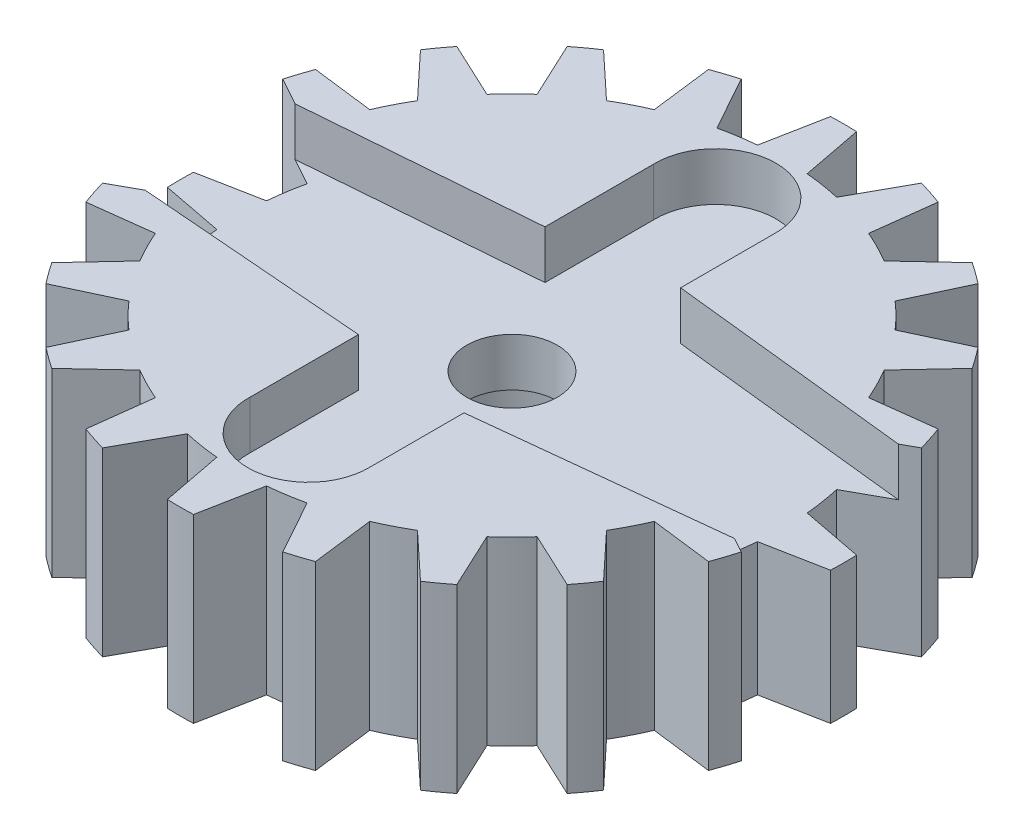
from build123d import *

# Parameters (mm, degrees)
SKETCH1_R           = 11
SKETCH1_R_2         = 1.5
BOSS_EXTRUDE1_DEPTH = 6
CUT_EXTRUDE1_DEPTH  = 6
CIRPATTERN1_COUNT   = 20
SKETCH3_R           = 1.25
CUT_EXTRUDE2_DEPTH  = 1.6
SKETCH4_R           = 2.6
CUT_EXTRUDE3_DEPTH  = 2.8


with BuildPart() as part:
    # Sketch1 → Boss-Extrude1 (new body)
    with BuildSketch(Plane(origin=(0, 0, 0), x_dir=(1, 0, 0), z_dir=(0, 1, 0))):
        Circle(SKETCH1_R)
        Circle(SKETCH1_R_2, mode=Mode.SUBTRACT)
    extrude(amount=BOSS_EXTRUDE1_DEPTH)

    # Sketch2 → Cut-Extrude1 (cut)
    with BuildSketch(Plane(origin=(0, 6, 0), x_dir=(1, 0, 0), z_dir=(0, 1, 0))):
        with BuildLine():
            Line((-0.823514568, 8.962244348), (-0.431857973, 10.991519399))
            ThreePointArc((-0.431857973, 10.991519399), (0, 11), (0.431857973, 10.991519399))
            Line((0.431857973, 10.991519399), (0.823514568, 8.962244348))
            ThreePointArc((0.823514568, 8.962244348), (1.116310063, 8.930501209), (1.407910185, 8.889195065))
            Line((1.407910185, 8.889195065), (2.683697474, 16.944198993))
            Line((2.683697474, 16.944198993), (-2.683697474, 16.944198993))
            Line((-2.683697474, 16.944198993), (-1.407910185, 8.889195065))
            ThreePointArc((-1.407910185, 8.889195065), (-1.116310063, 8.930501209), (-0.823514568, 8.962244348))
        make_face()
    cut_extrude1 = extrude(amount=-CUT_EXTRUDE1_DEPTH, mode=Mode.SUBTRACT)

    # CirPattern1: Cut-Extrude1 ×20 about axis
    cirpattern1_axis = Axis((0, 0, 0), (0, 1, 0))
    for i in range(1, CIRPATTERN1_COUNT):
        add(cut_extrude1.rotate(cirpattern1_axis, i * 360 / CIRPATTERN1_COUNT), mode=Mode.SUBTRACT)

    # Sketch3 → Cut-Extrude2 (cut)
    with BuildSketch(Plane(origin=(0, 6, 0), x_dir=(1, 0, 0), z_dir=(0, 1, 0))):
        with BuildLine():
            Line((-1.99882942, 6.681582528), (-1.99882942, 3.092373279))
            Line((-1.99882942, 3.092373279), (-15.754015296, 1.999995968))
            ThreePointArc((-15.754015296, 1.999995968), (-17.749999999, 0), (-15.754015296, -1.999995968))
            Line((-15.754015296, -1.999995968), (-1.99882942, -3.092373279))
            Line((-1.99882942, -3.092373279), (-1.99882942, -6.681582528))
            ThreePointArc((-1.99882942, -6.681582528), (0, -8.75), (1.99882942, -6.681582528))
            Line((1.99882942, -6.681582528), (1.99882942, -3.589755709))
            Line((1.99882942, -3.589755709), (15.756121614, -2.099991078))
            ThreePointArc((15.756121614, -2.099991078), (17.85, 0), (15.756121614, 2.099991078))
            Line((15.756121614, 2.099991078), (1.99882942, 3.589755709))
            Line((1.99882942, 3.589755709), (1.99882942, 6.681582528))
            ThreePointArc((1.99882942, 6.681582528), (0, 8.75), (-1.99882942, 6.681582528))
        make_face()
        Circle(SKETCH3_R, mode=Mode.SUBTRACT)
    extrude(amount=-CUT_EXTRUDE2_DEPTH, mode=Mode.SUBTRACT)

    # Sketch4 → Cut-Extrude3 (cut)
    with BuildSketch(Plane.XZ):
        Circle(SKETCH4_R)
    extrude(amount=-CUT_EXTRUDE3_DEPTH, mode=Mode.SUBTRACT)


solid = part.part
